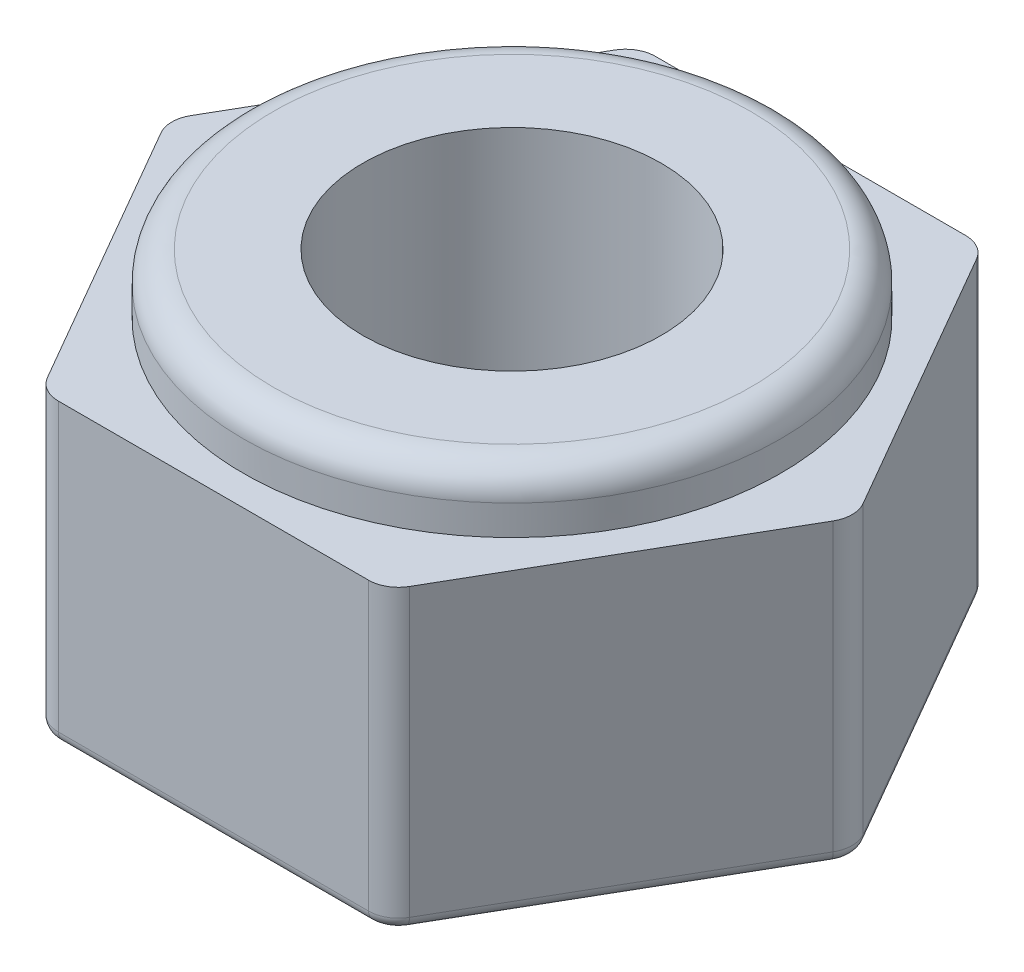
from build123d import *

# Parameters (mm, degrees)
CROQUIS1_R              = 2.5
SALIENTE_EXTRUIR1_DEPTH = 6
REDONDEO1_R             = 0.5
REDONDEO2_R             = 0.2
CROQUIS3_W              = 2.5
CROQUIS3_H              = 1
REDONDEO3_R             = 0.5


with BuildPart() as part:
    # Croquis1 → Saliente-Extruir1 (new body)
    with BuildSketch(Plane(origin=(0, 0, 0), x_dir=(1, 0, 0), z_dir=(0, 1, 0))):
        Polygon((-2.886751346, 5), (-5.773502692, 0), (-2.886751346, -5), (2.886751346, -5), (5.773502692, 0), (2.886751346, 5), align=None)
        Circle(CROQUIS1_R, mode=Mode.SUBTRACT)
    extrude(amount=SALIENTE_EXTRUIR1_DEPTH)

    # Redondeo1
    redondeo1_edges = [part.edges().sort_by_distance(p)[0] for p in [
        (2.886751346, 3, -5),
        (5.773502692, 3, 0),
        (2.886751346, 3, 5),
        (-2.886751346, 3, 5),
        (-5.773502692, 3, 0),
        (-2.886751346, 3, -5),
    ]]
    fillet(redondeo1_edges, radius=REDONDEO1_R)

    # Redondeo2
    redondeo2_edges = [part.edges().sort_by_distance(p)[0] for p in [
        (-4.330127019, 0, -2.5),
        (-4.330127019, 6, -2.5),
        (0, 0, -5),
        (4.330127019, 0, -2.5),
        (4.330127019, 0, 2.5),
        (0, 0, 5),
        (-4.330127019, 0, 2.5),
        (-2.848076211, 0, 4.933012702),
        (-5.696152423, 0, 0),
        (2.848076211, 0, 4.933012702),
        (5.696152423, 0, 0),
        (2.848076211, 0, -4.933012702),
        (-2.848076211, 0, -4.933012702),
        (0, 6, -5),
        (-4.330127019, 6, 2.5),
        (0, 6, 5),
        (4.330127019, 6, 2.5),
        (4.330127019, 6, -2.5),
        (-2.848076211, 6, 4.933012702),
        (-5.696152423, 6, 0),
        (2.848076211, 6, 4.933012702),
        (5.696152423, 6, 0),
        (2.848076211, 6, -4.933012702),
        (-2.848076211, 6, -4.933012702),
    ]]
    fillet(redondeo2_edges, radius=REDONDEO2_R)

    # Croquis3 → Cortar-Revolución1 (revolve, cut)
    with BuildSketch(Plane.XY):
        with Locations((-5.75, 5.5)):
            Rectangle(CROQUIS3_W, CROQUIS3_H)
    revolve(axis=Axis((0, 0, 0), (0, 1, 0)), mode=Mode.SUBTRACT)

    # Redondeo3
    redondeo3_edges = [part.edges().sort_by_distance(p)[0] for p in [
        (4.5, 6, 0),
    ]]
    fillet(redondeo3_edges, radius=REDONDEO3_R)


solid = part.part
